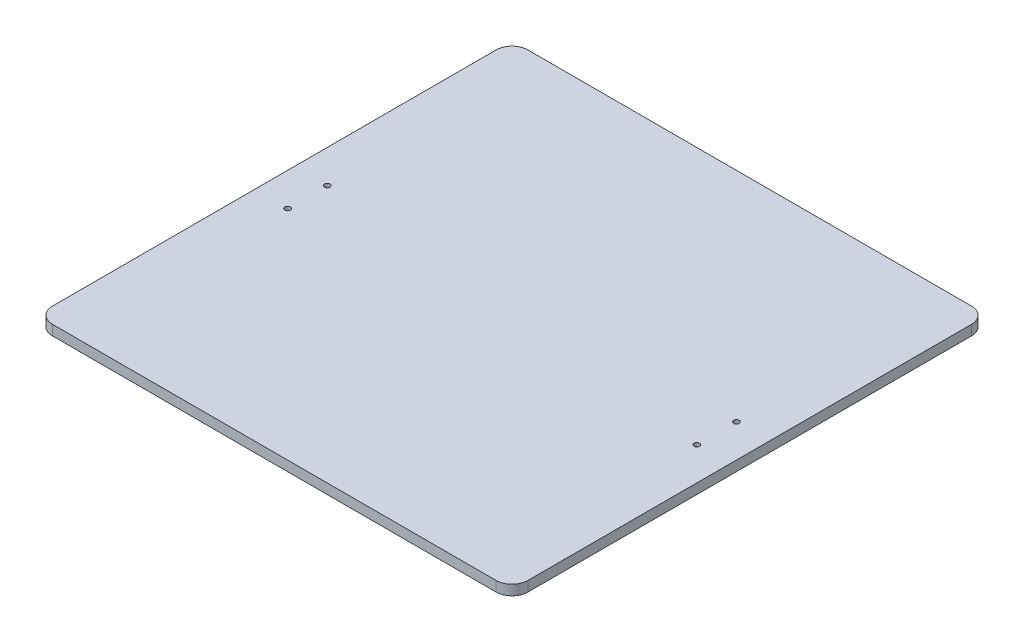
from build123d import *

# Parameters (mm, degrees)
SKETCH1_W           = 300
SKETCH1_H           = 300
BOSS_EXTRUDE1_DEPTH = 6.35
FILLET1_R           = 10
SKETCH2_R           = 1.75
CUT_EXTRUDE1_DEPTH  = 7.35


with BuildPart() as part:
    # Sketch1 → Boss-Extrude1 (new body)
    with BuildSketch(Plane(origin=(0, 0, 0), x_dir=(1, 0, 0), z_dir=(0, 1, 0))):
        Rectangle(SKETCH1_W, SKETCH1_H)
    extrude(amount=BOSS_EXTRUDE1_DEPTH)

    # Fillet1
    fillet1_edges = [part.edges().sort_by_distance(p)[0] for p in [
        (150, 3.175, 150),
        (-150, 3.175, 150),
        (-150, 3.175, -150),
        (150, 3.175, -150),
    ]]
    fillet(fillet1_edges, radius=FILLET1_R)

    # Sketch2 → Cut-Extrude1 (cut, through all)
    with BuildSketch(Plane(origin=(0, 6.35, 0), x_dir=(1, 0, 0), z_dir=(0, 1, 0))):
        with Locations((-129.12, 12.5)):
            Circle(SKETCH2_R)
        with Locations((-129.12, -12.5)):
            Circle(SKETCH2_R)
        with Locations((129.12, 12.5)):
            Circle(SKETCH2_R)
        with Locations((129.12, -12.5)):
            Circle(SKETCH2_R)
    extrude(amount=-CUT_EXTRUDE1_DEPTH, mode=Mode.SUBTRACT)


solid = part.part
